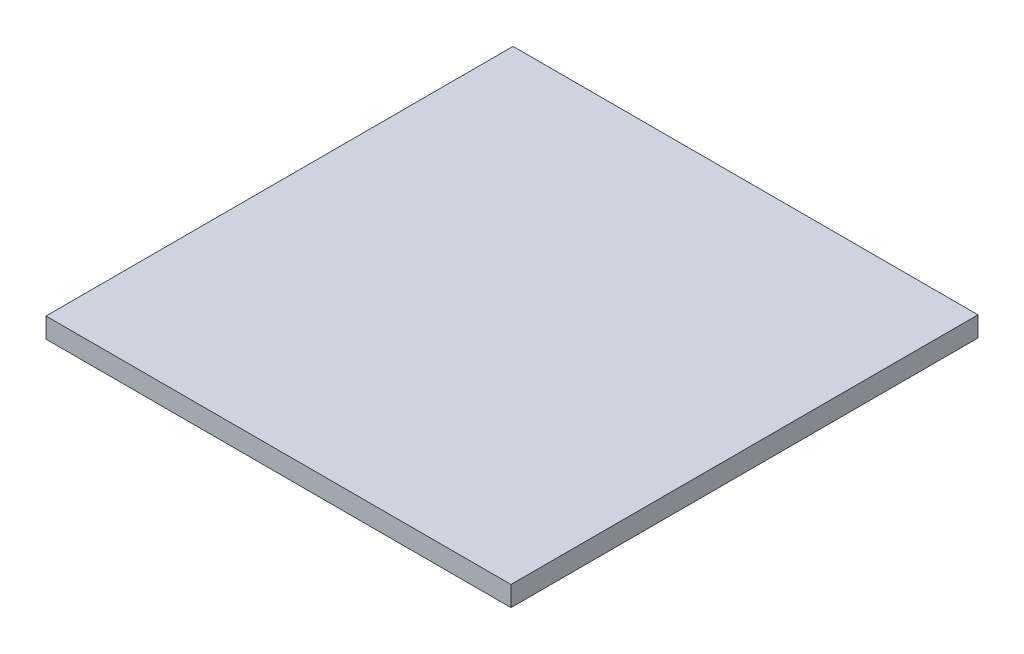
from build123d import *

# Parameters (mm, degrees)
SKETCH1_W           = 22
SKETCH1_H           = 22.098
BOSS_EXTRUDE1_DEPTH = 0.95


with BuildPart() as part:
    # Sketch1 → Boss-Extrude1 (new body)
    with BuildSketch(Plane(origin=(0, 0, 0), x_dir=(1, 0, 0), z_dir=(0, 1, 0))):
        with Locations((11, 11.049)):
            Rectangle(SKETCH1_W, SKETCH1_H)
    extrude(amount=BOSS_EXTRUDE1_DEPTH)


solid = part.part
